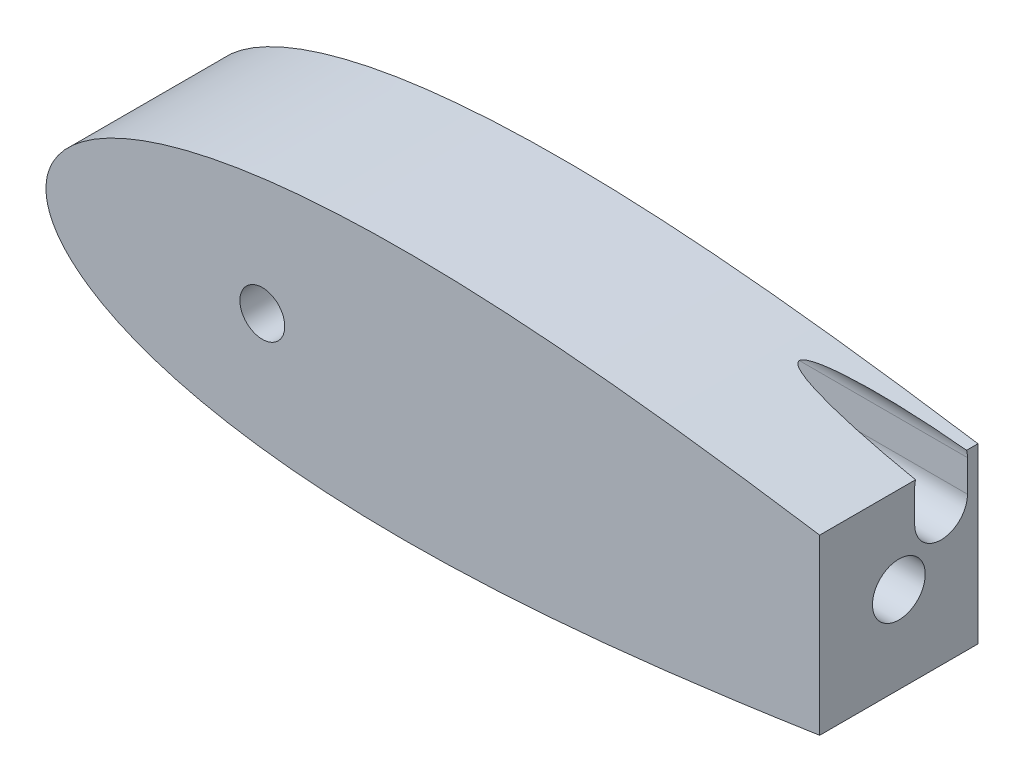
from build123d import *

# Parameters (mm, degrees)
BOSS_EXTRUDE1_DEPTH     = 76.2
SKETCH3_R               = 10.795
CUT_EXTRUDE2_DEPTH      = 76.2
SKETCH6_R               = 6.35
CUT_EXTRUDE3_DEPTH      = 53.34
CUT_EXTRUDE3_DEPTH_BACK = 0.000254
SKETCH7_R               = 1.5875
CUT_EXTRUDE4_DEPTH      = 30.48
SKETCH8_W               = 304.8
SKETCH8_H               = 127
CUT_EXTRUDE5_DEPTH      = 76.2
SKETCH9_R               = 12.7
CUT_EXTRUDE6_DEPTH      = 101.6
SKETCH10_R              = 3.175
CUT_EXTRUDE7_DEPTH      = 57.15
SKETCH11_R              = 5.08
CUT_EXTRUDE8_DEPTH      = 6.35
SKETCH12_R              = 3.175
CUT_EXTRUDE9_DEPTH      = 6.35
CUT_EXTRUDE10_DEPTH     = 198.458047838
SKETCH15_W              = 87.376
SKETCH15_H              = 60.96
CUT_EXTRUDE11_DEPTH     = 33.299999948


with BuildPart() as part:
    # Sketch1 → Boss-Extrude1 (new body)
    with BuildSketch(Plane.XY):
        with BuildLine():
            Line((643.966787522, 0), (643.599082689, 0))
            Line((643.599082689, 0), (643.599082689, -1.016))
            ThreePointArc((643.599082689, -1.016), (643.872033494, -0.540245973), (643.966787522, 0))
        make_face()
        with BuildLine():
            Line((643.599082689, -1.016), (643.599082689, 0))
            Line((643.599082689, 0), (641.567082689, 0))
            ThreePointArc((641.567082689, 0), (642.269121423, -1.135922533), (643.599082689, -1.016))
        make_face()
        with BuildLine():
            Line((641.567082689, 0), (643.599082689, 0))
            Line((643.599082689, 0), (643.966787522, 0))
            ThreePointArc((643.966787522, 0), (643.547407924, 1.075012082), (642.510849283, 1.582039112))
            add(Edge.make_bspline(
                [(642.510849283, 1.582039112), (641.993392355, 1.625070631), (638.093728429, 1.953546407), (630.413817462, 2.663385493), (619.014124193, 3.849253664), (606.374988512, 5.304428983), (592.543922516, 7.037634907), (577.585454095, 9.050636147), (561.564270734, 11.338919625), (544.549749946, 13.890665375), (526.614143658, 16.687720753), (507.832591566, 19.705111663), (488.282710288, 22.911672601), (468.044367735, 26.27043606), (447.199424328, 29.739007432), (425.831595832, 33.270324121), (404.02631566, 36.813220545), (381.870662856, 40.313266856), (359.453314895, 43.713502532), (336.86454415, 46.955447457), (314.196207315, 49.979843895), (291.541767704, 52.727712704), (268.996310773, 55.141201012), (246.65655865, 57.164603829), (224.620860897, 58.745176641), (202.989192599, 59.8341217), (181.863132616, 60.387506142), (161.345829027, 60.366961324), (141.542033828, 59.739895824), (122.558104573, 58.481758104), (104.502313427, 56.574303932), (87.485018636, 54.008935199), (71.619696083, 50.784752003), (57.023709725, 46.912543066), (43.82045433, 42.41500246), (32.141645239, 37.332204029), (22.129107375, 31.731455339), (13.932423524, 25.726412106), (7.689616489, 19.513207632), (3.463136343, 13.420354421), (1.106333228, 7.923389435), (0.154611582, 3.513796615), (0, 1.007496172), (0, 0)],
                knots=[0.020157042, 0.020157042, 0.020157042, 0.020157042, 0.021270888, 0.028552555, 0.036780684, 0.045920102, 0.055931764, 0.066772884, 0.07839713, 0.090754827, 0.103793165, 0.117456432, 0.131686226, 0.146421738, 0.161599998, 0.177156133, 0.193023668, 0.209134786, 0.225420633, 0.241811602, 0.258237647, 0.274628557, 0.290914287, 0.307025229, 0.322892517, 0.338448342, 0.353626207, 0.368361232, 0.382590428, 0.396252961, 0.409290412, 0.42164701, 0.433269881, 0.444109249, 0.45411864, 0.463255055, 0.471479114, 0.478755289, 0.485052318, 0.490344026, 0.494609833, 0.497833231, 0.5, 0.5, 0.5, 0.5], degree=3))
            Line((0, 0), (27.94, 0))
            ThreePointArc((27.94, 0), (40.64, 12.7), (53.34, 0))
            Line((53.34, 0), (93.345, 0))
            ThreePointArc((93.345, 0), (104.14, 10.795), (114.935, 0))
            Line((114.935, 0), (460.660965279, 0))
            Line((460.660965279, 0), (473.360965279, 0))
            Line((473.360965279, 0), (641.567082689, 0))
        make_face()
        with BuildLine():
            ThreePointArc((642.510849283, -1.582039112), (643.111845681, -1.408373102), (643.599082689, -1.016))
            ThreePointArc((643.599082689, -1.016), (642.269121423, -1.135922533), (641.567082689, 0))
            Line((641.567082689, 0), (473.360965279, 0))
            Line((473.360965279, 0), (460.660965279, 0))
            Line((460.660965279, 0), (114.935, 0))
            ThreePointArc((114.935, 0), (104.14, -10.795), (93.345, 0))
            Line((93.345, 0), (53.34, 0))
            ThreePointArc((53.34, 0), (40.64, -12.7), (27.94, 0))
            Line((27.94, 0), (0, 0))
            add(Edge.make_bspline(
                [(0, 0), (0, -1.007496172), (0.154611582, -3.513796615), (1.106333228, -7.923389435), (3.463136343, -13.420354421), (7.689616489, -19.513207632), (13.932423524, -25.726412106), (22.129107375, -31.731455339), (32.141645239, -37.332204029), (43.82045433, -42.41500246), (57.023709725, -46.912543066), (71.619696083, -50.784752003), (87.485018636, -54.008935199), (104.502313427, -56.574303932), (122.558104573, -58.481758104), (141.542033828, -59.739895824), (161.345829027, -60.366961324), (181.863132616, -60.387506142), (202.989192599, -59.8341217), (224.620860897, -58.745176641), (246.65655865, -57.164603829), (268.996310773, -55.141201012), (291.541767704, -52.727712704), (314.196207315, -49.979843895), (336.86454415, -46.955447457), (359.453314895, -43.713502532), (381.870662856, -40.313266856), (404.02631566, -36.813220545), (425.831595832, -33.270324121), (447.199424328, -29.739007432), (468.044367735, -26.27043606), (488.282710288, -22.911672601), (507.832591566, -19.705111663), (526.614143658, -16.687720753), (544.549749946, -13.890665375), (561.564270734, -11.338919625), (577.585454095, -9.050636147), (592.543922516, -7.037634907), (606.374988512, -5.304428983), (619.014124193, -3.849253664), (630.413817462, -2.663385493), (638.093728429, -1.953546407), (641.993392355, -1.625070631), (642.510849283, -1.582039112)],
                knots=[0.5, 0.5, 0.5, 0.5, 0.502166769, 0.505390167, 0.509655974, 0.514947682, 0.521244711, 0.528520886, 0.536744945, 0.54588136, 0.555890751, 0.566730119, 0.57835299, 0.590709588, 0.603747039, 0.617409572, 0.631638768, 0.646373793, 0.661551658, 0.677107483, 0.692974771, 0.709085713, 0.725371443, 0.741762353, 0.758188398, 0.774579367, 0.790865214, 0.806976332, 0.822843867, 0.838400002, 0.853578262, 0.868313774, 0.882543568, 0.896206835, 0.909245173, 0.92160287, 0.933227116, 0.944068236, 0.954079898, 0.963219316, 0.971447445, 0.978729112, 0.979842958, 0.979842958, 0.979842958, 0.979842958], degree=3))
        make_face()
        with BuildLine():
            ThreePointArc((643.966787522, 0), (643.872033494, -0.540245973), (643.599082689, -1.016))
            ThreePointArc((643.599082689, -1.016), (643.111845681, -1.408373102), (642.510849283, -1.582039112))
            add(Edge.make_bspline(
                [(642.510849283, -1.582039112), (644.922074617, -1.381522545), (649.798936594, -1.000308437), (656.504964311, -0.543558383), (662.850933168, -0.234427605), (666.344759683, -0.054696708), (670.56, -0.015678595), (670.56, 0)],
                knots=[0.979842958, 0.979842958, 0.979842958, 0.979842958, 0.985033212, 0.990332793, 0.994605218, 0.997832222, 1, 1, 1, 1], degree=3))
            add(Edge.make_bspline(
                [(670.56, 0), (670.56, 0.015678595), (666.344759683, 0.054696708), (662.850933168, 0.234427605), (656.504964311, 0.543558383), (649.798936594, 1.000308437), (644.922074617, 1.381522545), (642.510849283, 1.582039112)],
                knots=[0, 0, 0, 0, 0.002167778, 0.005394782, 0.009667207, 0.014966788, 0.020157042, 0.020157042, 0.020157042, 0.020157042], degree=3))
            ThreePointArc((642.510849283, 1.582039112), (643.547407924, 1.075012082), (643.966787522, 0))
        make_face()
        with BuildLine():
            ThreePointArc((53.34, 0), (40.64, 12.7), (27.94, 0))
            Line((27.94, 0), (53.34, 0))
        make_face()
        with BuildLine():
            Line((53.34, 0), (27.94, 0))
            ThreePointArc((27.94, 0), (40.64, -12.7), (53.34, 0))
        make_face()
        with BuildLine():
            ThreePointArc((93.345, 0), (104.14, -10.795), (114.935, 0))
            Line((114.935, 0), (93.345, 0))
        make_face()
        with BuildLine():
            Line((93.345, 0), (114.935, 0))
            ThreePointArc((114.935, 0), (104.14, 10.795), (93.345, 0))
        make_face()
    extrude(amount=BOSS_EXTRUDE1_DEPTH)

    # Sketch3 → Cut-Extrude2 (cut)
    with BuildSketch(Plane.XY.offset(76.2)):
        with Locations((104.139232412, 0)):
            Circle(SKETCH3_R)
    extrude(amount=-CUT_EXTRUDE2_DEPTH, mode=Mode.SUBTRACT)

    # Sketch6 → Cut-Extrude3 (cut, two sides)
    with BuildSketch(Plane(origin=(0, 0, 0), x_dir=(0, 0, -1), z_dir=(1, 0, 0))) as cut_extrude3_sk:
        with Locations((-20.32, 0)):
            Circle(SKETCH6_R)
    extrude(amount=CUT_EXTRUDE3_DEPTH, mode=Mode.SUBTRACT)
    extrude(cut_extrude3_sk.sketch, amount=-CUT_EXTRUDE3_DEPTH_BACK, mode=Mode.SUBTRACT)

    # Sketch7 → Cut-Extrude4 (cut)
    with BuildSketch(Plane(origin=(0, 0, 0), x_dir=(-1, 0, 0), z_dir=(0, 0, -1))):
        with Locations((-38.1, 0)):
            Circle(SKETCH7_R)
        with Locations((-50.8, 0)):
            Circle(SKETCH7_R)
    extrude(amount=-CUT_EXTRUDE4_DEPTH, mode=Mode.SUBTRACT)

    # Sketch8 → Cut-Extrude5 (cut)
    with BuildSketch(Plane(origin=(0, 0, 0), x_dir=(-1, 0, 0), z_dir=(0, 0, -1))):
        with Locations((-524.843319628, 0.490119432)):
            Rectangle(SKETCH8_W, SKETCH8_H)
    extrude(amount=-CUT_EXTRUDE5_DEPTH, mode=Mode.SUBTRACT)

    # Sketch9 → Cut-Extrude6 (cut)
    with BuildSketch(Plane(origin=(372.443319628, 0, 0), x_dir=(0, 0, -1), z_dir=(1, 0, 0))):
        with Locations((-38.1, 0)):
            Circle(SKETCH9_R)
    extrude(amount=-CUT_EXTRUDE6_DEPTH, mode=Mode.SUBTRACT)

    # Sketch10 → Cut-Extrude7 (cut)
    with BuildSketch(Plane(origin=(0, 0, 0), x_dir=(-1, 0, 0), z_dir=(0, 0, -1))):
        with Locations((-343.868319647, 0)):
            Circle(SKETCH10_R)
        with Locations((-286.718319647, 0)):
            Circle(SKETCH10_R)
    extrude(amount=-CUT_EXTRUDE7_DEPTH, mode=Mode.SUBTRACT)

    # Sketch11 → Cut-Extrude8 (cut)
    with BuildSketch(Plane(origin=(0, 0, 0), x_dir=(-1, 0, 0), z_dir=(0, 0, -1))):
        with Locations((-286.718319647, 0)):
            Circle(SKETCH11_R)
        with Locations((-343.868319647, 0)):
            Circle(SKETCH11_R)
    extrude(amount=-CUT_EXTRUDE8_DEPTH, mode=Mode.SUBTRACT)

    # Sketch12 → Cut-Extrude9 (cut)
    with BuildSketch(Plane(origin=(0, 0, 0), x_dir=(-1, 0, 0), z_dir=(0, 0, -1))):
        with Locations((-38.1, 0)):
            Circle(SKETCH12_R)
        with Locations((-50.8, 0)):
            Circle(SKETCH12_R)
    extrude(amount=-CUT_EXTRUDE9_DEPTH, mode=Mode.SUBTRACT)

    # Sketch13 → Cut-Extrude10 (cut)
    with BuildSketch(Plane(origin=(372.443319628, 0, 0), x_dir=(0, 0, -1), z_dir=(1, 0, 0))):
        with BuildLine():
            Line((-30.48, 23.232341673), (-30.48, 38.472341673))
            ThreePointArc((-30.48, 38.472341673), (-17.78, 51.172341673), (-5.08, 38.472341673))
            Line((-5.08, 38.472341673), (-5.08, 23.232341673))
            ThreePointArc((-5.08, 23.232341673), (-17.78, 10.532341673), (-30.48, 23.232341673))
        make_face()
    extrude(amount=-CUT_EXTRUDE10_DEPTH, mode=Mode.SUBTRACT)

    # Sketch15 → Cut-Extrude11 (cut)
    with BuildSketch(Plane(origin=(0, 0, 0), x_dir=(-1, 0, 0), z_dir=(0, 0, -1))):
        with Locations((-217.673271809, 0)):
            Rectangle(SKETCH15_W, SKETCH15_H)
    extrude(amount=-CUT_EXTRUDE11_DEPTH, mode=Mode.SUBTRACT)


solid = part.part
